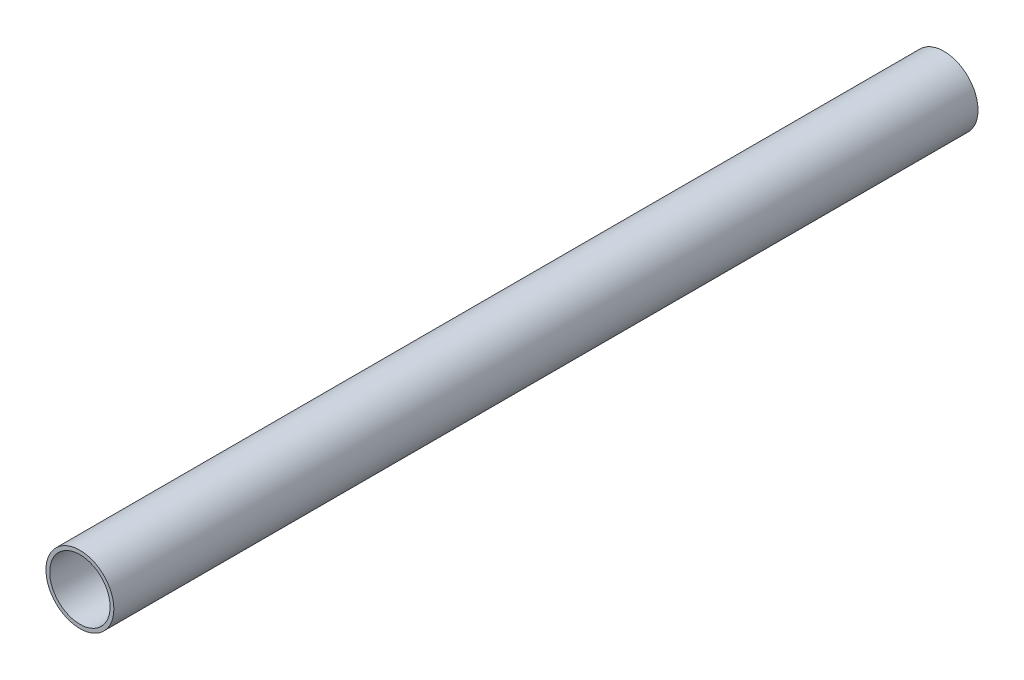
from build123d import *

# Parameters (mm, degrees)
SZKIC1_R                    = 13.5
SZKIC1_R_2                  = 12
DODANIE_WYCI_GNI_CIE1_DEPTH = 343.5


with BuildPart() as part:
    # Szkic1 → Dodanie-wyciągnięcie1 (new body)
    with BuildSketch(Plane.XY):
        Circle(SZKIC1_R)
        Circle(SZKIC1_R_2, mode=Mode.SUBTRACT)
    extrude(amount=DODANIE_WYCI_GNI_CIE1_DEPTH)


solid = part.part
